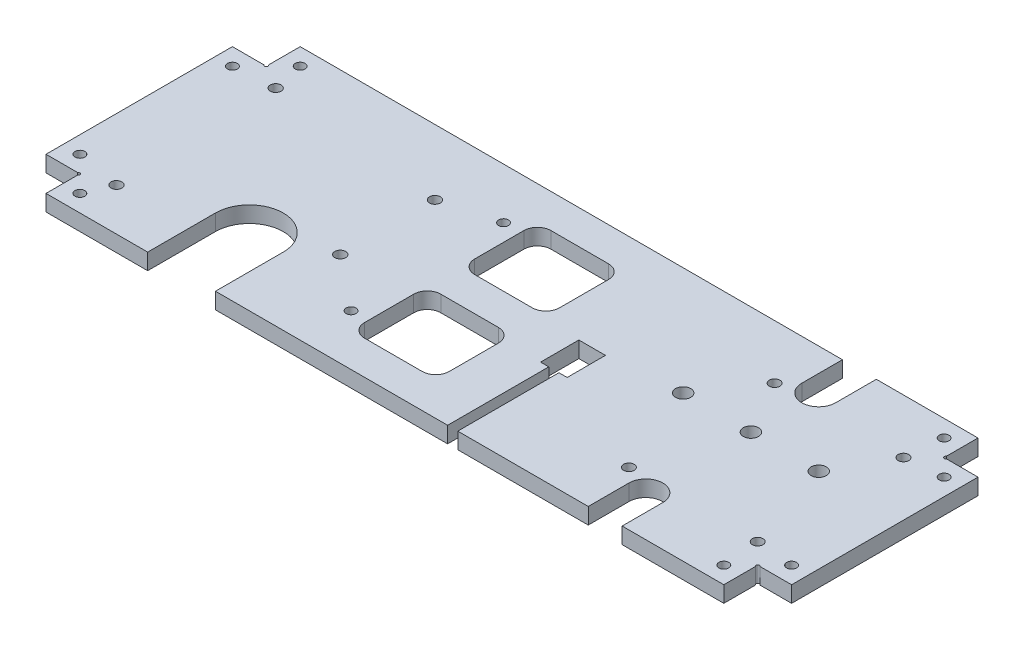
from build123d import *

# Parameters (mm, degrees)
SKETCH1_R           = 1.45
BOSS_EXTRUDE1_DEPTH = 4.7625
SKETCH2_R           = 1.45
SKETCH2_R_2         = 1.6
SKETCH2_R_3         = 2.25
SKETCH2_R_4         = 1.5625
SKETCH2_W           = 25
SKETCH2_H           = 22.5
CUT_EXTRUDE1_DEPTH  = 5.7625
SKETCH3_R           = 0.5
CUT_EXTRUDE2_DEPTH  = 5.7625
FILLET1_R           = 4


with BuildPart() as part:
    # Sketch1 → Boss-Extrude1 (new body)
    with BuildSketch(Plane(origin=(0, 0, 0), x_dir=(1, 0, 0), z_dir=(0, 1, 0))):
        Polygon((100, 37.5), (100, 27.5), (110, 27.5), (110, -27.5), (100, -27.5), (100, -37.5), (-100, -37.5), (-100, -27.5), (-110, -27.5), (-110, 27.5), (-100, 27.5), (-100, 37.5), align=None)
        with Locations((-95, 32.5)):
            Circle(SKETCH1_R, mode=Mode.SUBTRACT)
        with Locations((-105, 22.5)):
            Circle(SKETCH1_R, mode=Mode.SUBTRACT)
        with Locations((105, 22.5)):
            Circle(SKETCH1_R, mode=Mode.SUBTRACT)
        with Locations((95, 32.5)):
            Circle(SKETCH1_R, mode=Mode.SUBTRACT)
        with Locations((-105, -22.5)):
            Circle(SKETCH1_R, mode=Mode.SUBTRACT)
        with Locations((-95, -32.5)):
            Circle(SKETCH1_R, mode=Mode.SUBTRACT)
        with Locations((95, -32.5)):
            Circle(SKETCH1_R, mode=Mode.SUBTRACT)
        with Locations((105, -22.5)):
            Circle(SKETCH1_R, mode=Mode.SUBTRACT)
    extrude(amount=BOSS_EXTRUDE1_DEPTH)

    # Sketch2 → Cut-Extrude1 (cut, through all)
    with BuildSketch(Plane(origin=(0, 4.7625, 0), x_dir=(1, 0, 0), z_dir=(0, 1, 0))):
        with Locations((-25, -22.5)):
            Circle(SKETCH2_R)
        with Locations((-25, 22.5)):
            Circle(SKETCH2_R)
        with Locations((-91.76, -24.96)):
            Circle(SKETCH2_R_2)
        with Locations((-93.03, 23.3)):
            Circle(SKETCH2_R_2)
        with Locations((-40.96, -9.72)):
            Circle(SKETCH2_R_2)
        with Locations((-40.96, 18.22)):
            Circle(SKETCH2_R_2)
        with Locations((45, 5.5)):
            Circle(SKETCH2_R_3)
        with Locations((65, 5.5)):
            Circle(SKETCH2_R_3)
        with Locations((85, 5.5)):
            Circle(SKETCH2_R_3)
        with Locations((56, -21.5)):
            Circle(SKETCH2_R_4)
        with Locations((94, -21.5)):
            Circle(SKETCH2_R_4)
        with Locations((94, 21.5)):
            Circle(SKETCH2_R_4)
        with Locations((56, 21.5)):
            Circle(SKETCH2_R_4)
        Polygon((16.075, 3.65), (23.925, 3.65), (23.925, -7.65), (21.5, -7.65), (21.5, -37.5), (18.5, -37.5), (18.5, -7.65), (16.075, -7.65), align=None)
        with BuildLine():
            Line((70, 37.5), (70, 25.5))
            ThreePointArc((70, 25.5), (65, 20.5), (60, 25.5))
            Line((60, 25.5), (60, 37.5))
            ThreePointArc((60, 37.5), (65, 42.5), (70, 37.5))
        make_face()
        with BuildLine():
            Line((60, -37.5), (60, -25.5))
            ThreePointArc((60, -25.5), (65, -20.5), (70, -25.5))
            Line((70, -25.5), (70, -37.5))
            ThreePointArc((70, -37.5), (65, -42.5), (60, -37.5))
        make_face()
        with Locations((-7.5, -16.25)):
            Rectangle(SKETCH2_W, SKETCH2_H)
        with Locations((-7.5, 16.25)):
            Rectangle(SKETCH2_W, SKETCH2_H)
        with BuildLine():
            Line((-70, -37.5), (-70, -17.5))
            ThreePointArc((-70, -17.5), (-60, -7.5), (-50, -17.5))
            Line((-50, -17.5), (-50, -37.5))
            ThreePointArc((-50, -37.5), (-60, -47.5), (-70, -37.5))
        make_face()
    extrude(amount=-CUT_EXTRUDE1_DEPTH, mode=Mode.SUBTRACT)

    # Sketch3 → Cut-Extrude2 (cut, through all)
    with BuildSketch(Plane(origin=(0, 4.7625, 0), x_dir=(1, 0, 0), z_dir=(0, 1, 0))):
        with Locations((-100.25, 27.75)):
            Circle(SKETCH3_R)
        with Locations((-100.25, -27.75)):
            Circle(SKETCH3_R)
        with Locations((100.25, -27.75)):
            Circle(SKETCH3_R)
        with Locations((100.25, 27.75)):
            Circle(SKETCH3_R)
    extrude(amount=-CUT_EXTRUDE2_DEPTH, mode=Mode.SUBTRACT)

    # Fillet1
    fillet1_edges = [part.edges().sort_by_distance(p)[0] for p in [
        (-20, 2.38125, 27.5),
        (-20, 2.38125, 5),
        (5, 2.38125, 5),
        (5, 2.38125, 27.5),
        (-20, 2.38125, -5),
        (-20, 2.38125, -27.5),
        (5, 2.38125, -27.5),
        (5, 2.38125, -5),
    ]]
    fillet(fillet1_edges, radius=FILLET1_R)


solid = part.part
